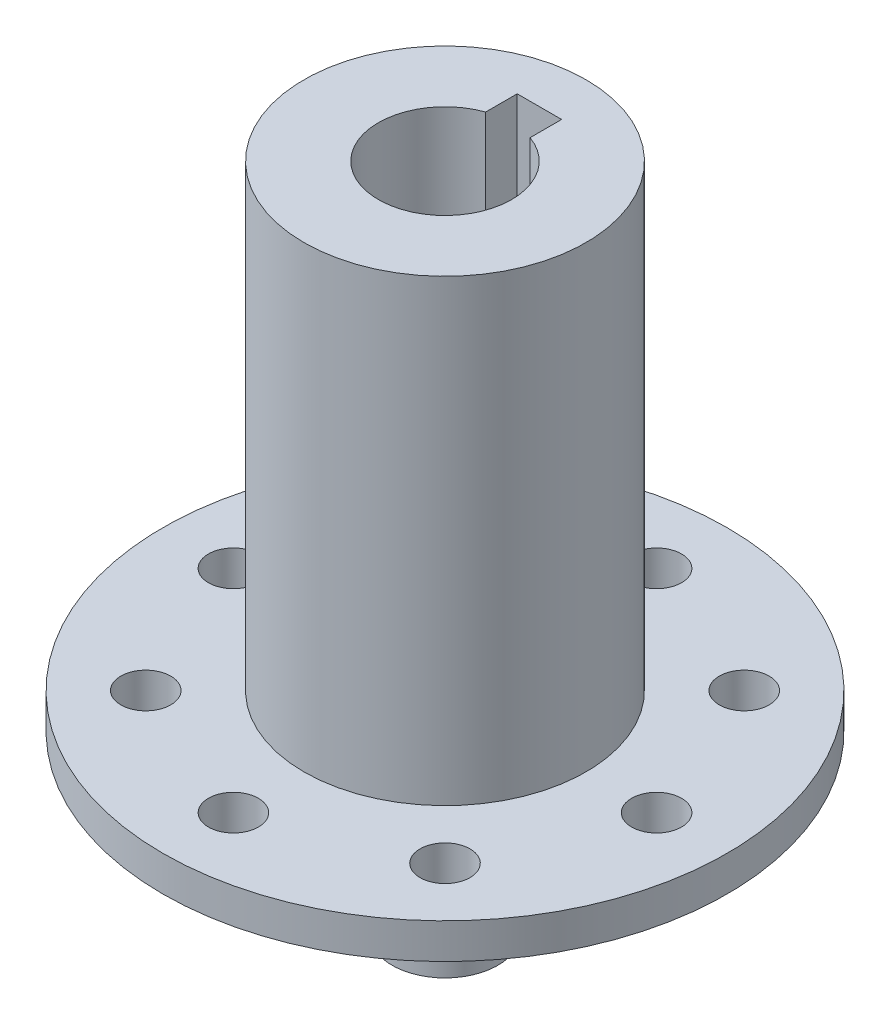
from build123d import *

# Parameters (mm, degrees)
SKETCH1_R                   = 12.7
BOSS_EXTRUDE1_DEPTH         = 41.275
SKETCH3_R                   = 25.4
BOSS_EXTRUDE3_DEPTH         = 3.175
F_8_CLEARANCE_HOLE1_D       = 4.4958
F_20_8MMTOENDOFKEYWAY_DEPTH = 25
SKETCH8_R                   = 4.7625
BOSS_EXTRUDE4_DEPTH         = 15.875
FILLET1_R                   = 5


with BuildPart() as part:
    # Sketch1 → Boss-Extrude1 (new body)
    with BuildSketch(Plane(origin=(0, 0, 0), x_dir=(1, 0, 0), z_dir=(0, 1, 0))):
        Circle(SKETCH1_R)
    extrude(amount=BOSS_EXTRUDE1_DEPTH)

    # Sketch3 → Boss-Extrude3 (add)
    with BuildSketch(Plane.XZ):
        Circle(SKETCH3_R)
    extrude(amount=BOSS_EXTRUDE3_DEPTH)

    # #8 Clearance Hole1 (through all)
    with Locations(Plane(origin=(0, -3.175, 0), x_dir=(-1, 0, 0), z_dir=(0, -1, 0))):
        with Locations((0, 19.05), (-13.470384182, 13.470384182), (-19.05, 0), (-13.470384182, -13.470384182), (0, -19.05), (13.470384182, -13.470384182), (19.05, 0), (13.470384182, 13.470384182)):
            Hole(F_8_CLEARANCE_HOLE1_D / 2)

    # Sketch7 → 20.8mmToEndofKeyway (cut)
    with BuildSketch(Plane(origin=(0, 41.275, 0), x_dir=(1, 0, 0), z_dir=(0, 1, 0))):
        with BuildLine():
            Line((-2, 8.5), (2, 8.5))
            Line((2, 8.5), (2, 5.656854249))
            ThreePointArc((2, 5.656854249), (0, -6), (-2, 5.656854249))
            Line((-2, 5.656854249), (-2, 8.5))
        make_face()
    extrude(amount=-F_20_8MMTOENDOFKEYWAY_DEPTH, mode=Mode.SUBTRACT)

    # Sketch8 → Boss-Extrude4 (add)
    with BuildSketch(Plane.XZ.offset(3.175)):
        Circle(SKETCH8_R)
    extrude(amount=BOSS_EXTRUDE4_DEPTH)

    # Fillet1
    fillet1_edges = [part.edges().sort_by_distance(p)[0] for p in [
        (-4.7625, -3.175, 0),
    ]]
    fillet(fillet1_edges, radius=FILLET1_R)


solid = part.part
